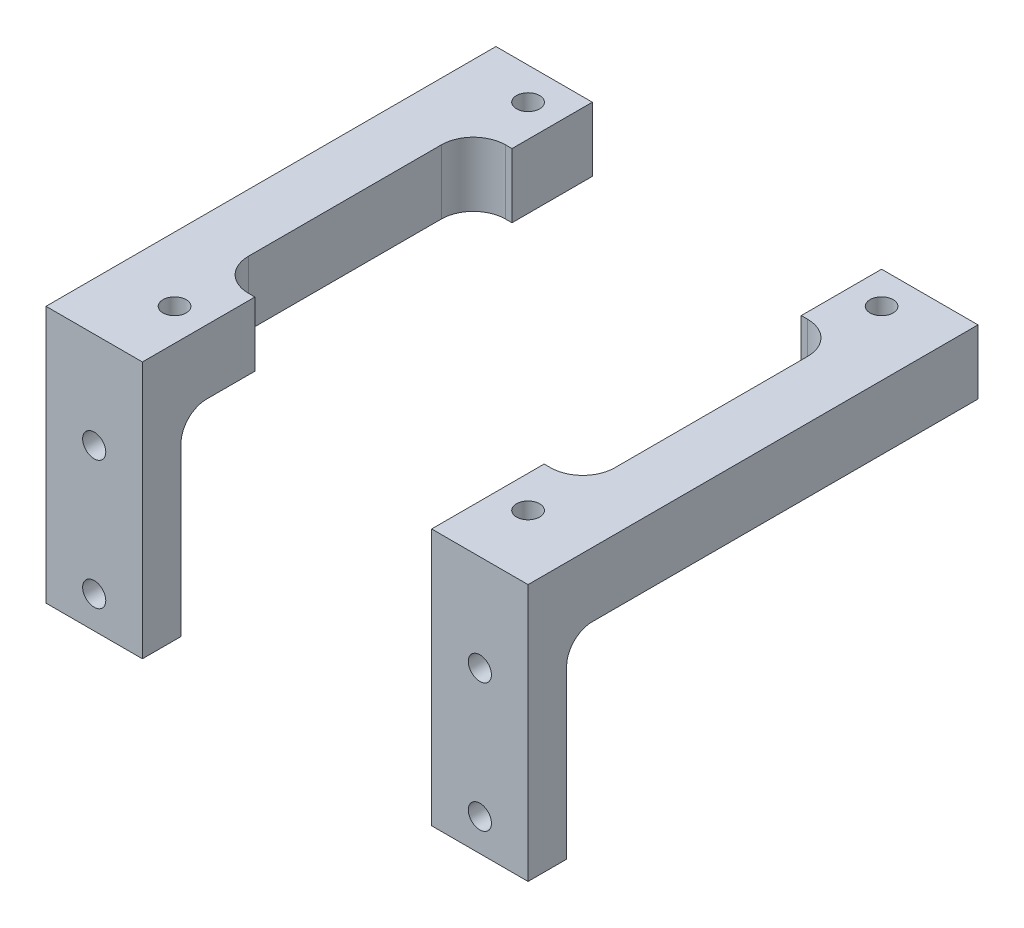
from build123d import *

# Parameters (mm, degrees)
SKETCH2_W           = 47.625
SKETCH2_H           = 25.4
BOSS_EXTRUDE1_DEPTH = 44.45
SKETCH3_W           = 28.575
SKETCH3_H           = 44.45
CUT_EXTRUDE1_DEPTH  = 26.4
SKETCH4_W           = 40.64
SKETCH4_H           = 19.05
CUT_EXTRUDE2_DEPTH  = 48.625
FILLET1_R           = 2.54
FILLET2_R           = 2.54
SKETCH5_R           = 1.143
CUT_EXTRUDE3_DEPTH  = 45.45
SKETCH6_R           = 1.143
CUT_EXTRUDE4_DEPTH  = 45.45
SKETCH7_R           = 1.143
CUT_EXTRUDE5_DEPTH  = 10.16
SKETCH8_W           = 36.195
SKETCH8_H           = 25.4
CUT_EXTRUDE6_DEPTH  = 26.4
FILLET3_R           = 3.175
FILLET4_R           = 3.175


with BuildPart() as part:
    # Sketch2 → Boss-Extrude1 (new body)
    with BuildSketch(Plane.XY):
        Rectangle(SKETCH2_W, SKETCH2_H)
    extrude(amount=BOSS_EXTRUDE1_DEPTH)

    # Sketch3 → Cut-Extrude1 (cut, through all)
    with BuildSketch(Plane(origin=(0, 12.7, 0), x_dir=(1, 0, 0), z_dir=(0, 1, 0))):
        with Locations((0, -22.225)):
            Rectangle(SKETCH3_W, SKETCH3_H)
    extrude(amount=-CUT_EXTRUDE1_DEPTH, mode=Mode.SUBTRACT)

    # Sketch4 → Cut-Extrude2 (cut, through all)
    with BuildSketch(Plane.ZY.offset(23.8125)):
        with Locations((20.32, -3.175)):
            Rectangle(SKETCH4_W, SKETCH4_H)
    extrude(amount=-CUT_EXTRUDE2_DEPTH, mode=Mode.SUBTRACT)

    # Fillet1
    fillet1_edges = [part.edges().sort_by_distance(p)[0] for p in [
        (19.05, 6.35, 40.64),
    ]]
    fillet(fillet1_edges, radius=FILLET1_R)

    # Fillet2
    fillet2_edges = [part.edges().sort_by_distance(p)[0] for p in [
        (-19.05, 6.35, 40.64),
    ]]
    fillet(fillet2_edges, radius=FILLET2_R)

    # Sketch5 → Cut-Extrude3 (cut, through all)
    with BuildSketch(Plane.XY.offset(44.45)):
        with Locations((-19.05, -9.525)):
            Circle(SKETCH5_R)
        with Locations((-19.05, 3.175)):
            Circle(SKETCH5_R)
    extrude(amount=-CUT_EXTRUDE3_DEPTH, mode=Mode.SUBTRACT)

    # Sketch6 → Cut-Extrude4 (cut, through all)
    with BuildSketch(Plane.XY.offset(44.45)):
        with Locations((19.05, -9.525)):
            Circle(SKETCH6_R)
        with Locations((19.05, 3.175)):
            Circle(SKETCH6_R)
    extrude(amount=-CUT_EXTRUDE4_DEPTH, mode=Mode.SUBTRACT)

    # Sketch7 → Cut-Extrude5 (cut)
    with BuildSketch(Plane(origin=(0, 12.7, 0), x_dir=(1, 0, 0), z_dir=(0, 1, 0))):
        with Locations((-17.4625, -38.1)):
            Circle(SKETCH7_R)
        with Locations((17.4625, -38.1)):
            Circle(SKETCH7_R)
        with Locations((-17.4625, -3.175)):
            Circle(SKETCH7_R)
        with Locations((17.4625, -3.175)):
            Circle(SKETCH7_R)
    extrude(amount=-CUT_EXTRUDE5_DEPTH, mode=Mode.SUBTRACT)

    # Sketch8 → Cut-Extrude6 (cut, through all)
    with BuildSketch(Plane(origin=(0, 12.7, 0), x_dir=(1, 0, 0), z_dir=(0, 1, 0))):
        with Locations((0, -20.6375)):
            Rectangle(SKETCH8_W, SKETCH8_H)
    extrude(amount=-CUT_EXTRUDE6_DEPTH, mode=Mode.SUBTRACT)

    # Fillet3
    fillet3_edges = [part.edges().sort_by_distance(p)[0] for p in [
        (-18.0975, 9.525, 33.3375),
        (-18.0975, 9.525, 7.9375),
    ]]
    fillet(fillet3_edges, radius=FILLET3_R)

    # Fillet4
    fillet4_edges = [part.edges().sort_by_distance(p)[0] for p in [
        (18.0975, 9.525, 7.9375),
        (18.0975, 9.525, 33.3375),
    ]]
    fillet(fillet4_edges, radius=FILLET4_R)


solid = part.part
